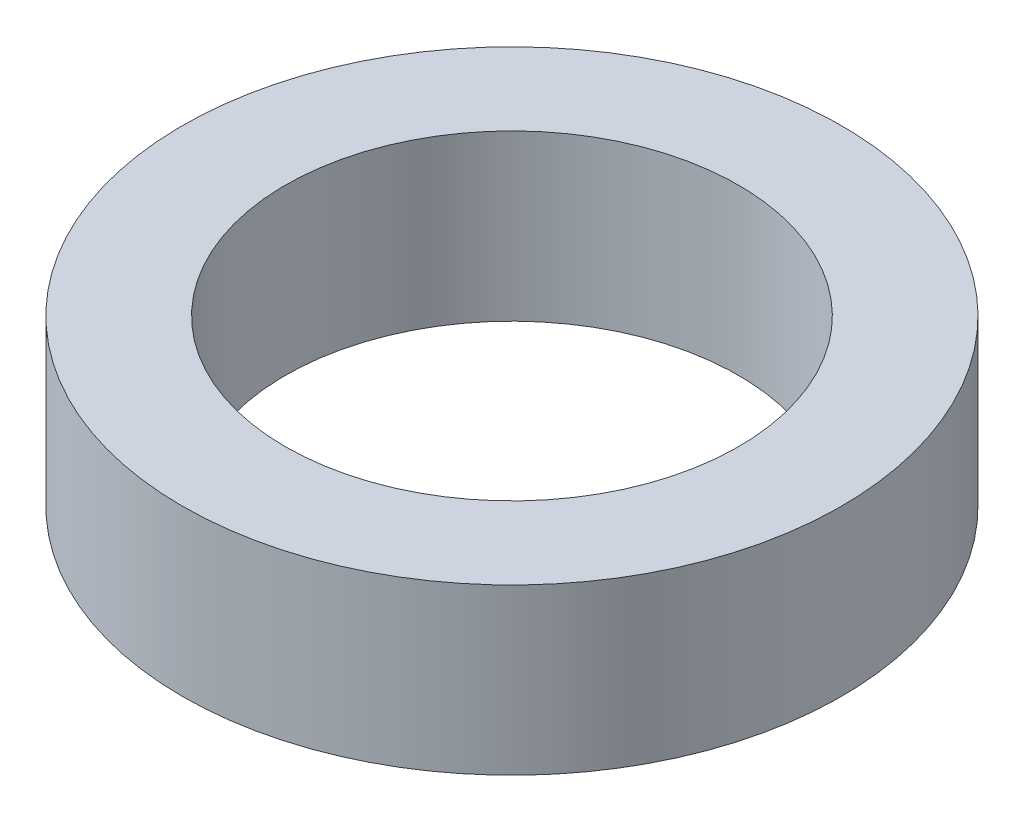
from build123d import *

# Parameters (mm, degrees)
SKETCH1_R           = 3.175
SKETCH1_R_2         = 2.1828125
BOSS_EXTRUDE1_DEPTH = 1.5875


with BuildPart() as part:
    # Sketch1 → Boss-Extrude1 (new body)
    with BuildSketch(Plane(origin=(0, 0, 0), x_dir=(1, 0, 0), z_dir=(0, 1, 0))):
        Circle(SKETCH1_R)
        Circle(SKETCH1_R_2, mode=Mode.SUBTRACT)
    extrude(amount=BOSS_EXTRUDE1_DEPTH)


solid = part.part
